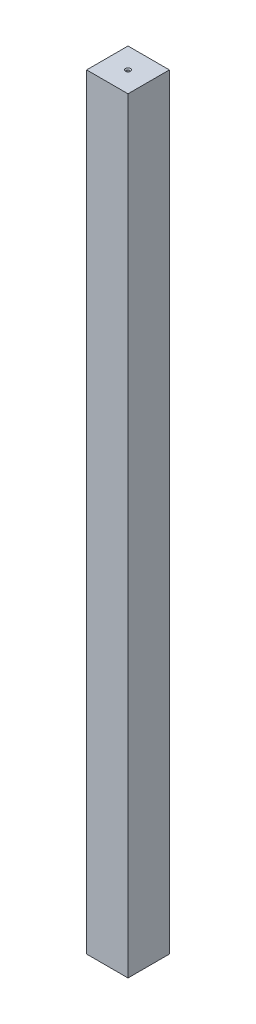
from build123d import *

# Parameters (mm, degrees)
SKETCH1_W           = 25.4
SKETCH1_H           = 25.4
BOSS_EXTRUDE1_DEPTH = 235


with BuildPart() as part:
    # Sketch1 → Boss-Extrude1 (new body, symmetric)
    with BuildSketch(Plane(origin=(0, 0, 0), x_dir=(1, 0, 0), z_dir=(0, 1, 0))):
        Rectangle(SKETCH1_W, SKETCH1_H)
    extrude(amount=BOSS_EXTRUDE1_DEPTH, both=True)

    # Sketch3 → CSK for #0 Flat Head Machine Screw (100)1 (revolve, cut)
    with BuildSketch(Plane(origin=(0, 235, 0), x_dir=(0, 0, 1), z_dir=(1, 0, 0))):
        Polygon((0, 0), (0, 32.234564046), (0.80645, 31.75), (0.80645, 0.591439375), (1.5113, 0), align=None)
    csk_for_0_flat_head_machine_screw_100 = revolve(axis=Axis((0, 241.35, 0), (0, -1, 0)), mode=Mode.SUBTRACT)

    # Mirror1: CSK for #0 Flat Head Machine Screw (100)1 across plane
    add(csk_for_0_flat_head_machine_screw_100.mirror(Plane.ZX), mode=Mode.SUBTRACT)


solid = part.part
